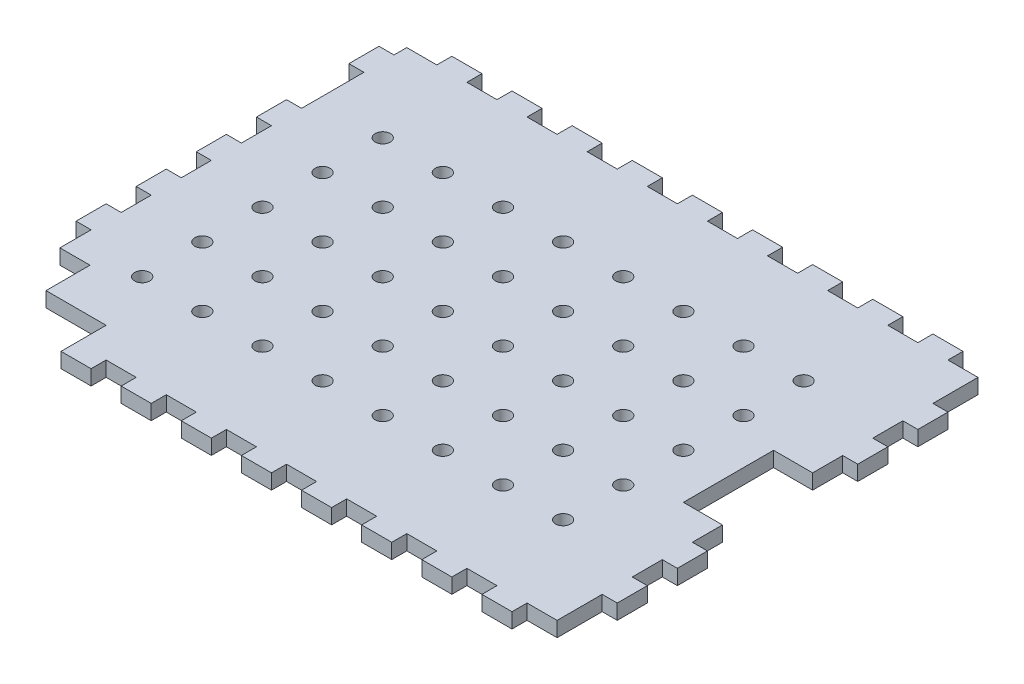
from build123d import *

# Parameters (mm, degrees)
SALIENTE_EXTRUIR1_DEPTH = 5
CROQUIS2_R              = 2.5
CORTAR_EXTRUIR1_DEPTH   = 10


with BuildPart() as part:
    # Croquis1 → Saliente-Extruir1 (new body)
    with BuildSketch(Plane(origin=(0, 0, 0), x_dir=(1, 0, 0), z_dir=(0, 1, 0))):
        Polygon((15, 5), (15, 0), (25, 0), (25, 5), (35, 5), (35, 0), (45, 0), (45, 5), (55, 5), (55, 0), (65, 0), (65, 5), (75, 5), (75, 0), (85, 0), (85, 5), (95, 5), (95, 0), (105, 0), (105, 5), (115, 5), (115, 0), (125, 0), (125, 5), (135, 5), (135, 0), (145, 0), (145, 5), (155, 5), (155, 0), (165, 0), (165, 5), (175, 5), (175, 0), (185, 0), (185, 5), (195, 5), (195, 20), (200, 20), (200, 30), (195, 30), (195, 40), (200, 40), (200, 50), (195, 50), (195, 60), (200, 60), (200, 70), (195, 70), (195, 80), (200, 80), (200, 90), (195, 90), (195, 100), (200, 100), (200, 110), (195, 110), (195, 120), (200, 120), (200, 130), (195, 130), (195, 145), (185, 145), (185, 150), (175, 150), (175, 145), (165, 145), (165, 150), (155, 150), (155, 145), (145, 145), (145, 150), (135, 150), (135, 145), (125, 145), (125, 150), (115, 150), (115, 145), (105, 145), (105, 150), (95, 150), (95, 145), (85, 145), (85, 150), (75, 150), (75, 145), (65, 145), (65, 150), (55, 150), (55, 145), (45, 145), (45, 150), (35, 150), (35, 145), (25, 145), (25, 150), (15, 150), (15, 145), (5, 145), (5, 140.75), (0, 140.75), (0, 130.75), (5, 130.75), (5, 110), (0, 110), (0, 100), (5, 100), (5, 90), (0, 90), (0, 80), (5, 80), (5, 70), (0, 70), (0, 60), (5, 60), (5, 50), (0, 50), (0, 40), (5, 40), (5, 19.25), (0, 19.25), (0, 9.25), (5, 9.25), (5, 5), align=None)
    extrude(amount=SALIENTE_EXTRUIR1_DEPTH)

    # Croquis2 → Cortar-Extruir1 (cut)
    with BuildSketch(Plane(origin=(0, 5, 0), x_dir=(1, 0, 0), z_dir=(0, 1, 0))):
        with Locations((27, 115)):
            Circle(CROQUIS2_R)
        with Locations((47, 115)):
            Circle(CROQUIS2_R)
        with Locations((67, 115)):
            Circle(CROQUIS2_R)
        with Locations((87, 115)):
            Circle(CROQUIS2_R)
        with Locations((107, 115)):
            Circle(CROQUIS2_R)
        with Locations((127, 115)):
            Circle(CROQUIS2_R)
        with Locations((147, 115)):
            Circle(CROQUIS2_R)
        with Locations((167, 115)):
            Circle(CROQUIS2_R)
        with Locations((47, 95)):
            Circle(CROQUIS2_R)
        with Locations((67, 95)):
            Circle(CROQUIS2_R)
        with Locations((87, 95)):
            Circle(CROQUIS2_R)
        with Locations((107, 95)):
            Circle(CROQUIS2_R)
        with Locations((127, 95)):
            Circle(CROQUIS2_R)
        with Locations((147, 95)):
            Circle(CROQUIS2_R)
        with Locations((167, 95)):
            Circle(CROQUIS2_R)
        with Locations((47, 75)):
            Circle(CROQUIS2_R)
        with Locations((67, 75)):
            Circle(CROQUIS2_R)
        with Locations((87, 75)):
            Circle(CROQUIS2_R)
        with Locations((107, 75)):
            Circle(CROQUIS2_R)
        with Locations((127, 75)):
            Circle(CROQUIS2_R)
        with Locations((147, 75)):
            Circle(CROQUIS2_R)
        with Locations((167, 75)):
            Circle(CROQUIS2_R)
        with Locations((47, 55)):
            Circle(CROQUIS2_R)
        with Locations((67, 55)):
            Circle(CROQUIS2_R)
        with Locations((87, 55)):
            Circle(CROQUIS2_R)
        with Locations((107, 55)):
            Circle(CROQUIS2_R)
        with Locations((127, 55)):
            Circle(CROQUIS2_R)
        with Locations((147, 55)):
            Circle(CROQUIS2_R)
        with Locations((167, 55)):
            Circle(CROQUIS2_R)
        with Locations((47, 35)):
            Circle(CROQUIS2_R)
        with Locations((67, 35)):
            Circle(CROQUIS2_R)
        with Locations((87, 35)):
            Circle(CROQUIS2_R)
        with Locations((107, 35)):
            Circle(CROQUIS2_R)
        with Locations((127, 35)):
            Circle(CROQUIS2_R)
        with Locations((147, 35)):
            Circle(CROQUIS2_R)
        with Locations((167, 35)):
            Circle(CROQUIS2_R)
        with Locations((27, 95)):
            Circle(CROQUIS2_R)
        with Locations((27, 75)):
            Circle(CROQUIS2_R)
        with Locations((27, 55)):
            Circle(CROQUIS2_R)
        with Locations((27, 35)):
            Circle(CROQUIS2_R)
        Polygon((5, 29.625), (5, 19.25), (0, 19.25), (0, 9.25), (5, 9.25), (5, 5), (15, 5), (15, 0), (25, 0), (25, 5), (35, 5), (35, 15), (15, 15), (15, 29.625), align=None)
        Polygon((195, 90), (200, 90), (200, 80), (195, 80), (195, 70), (200, 70), (200, 60), (195, 60), (182, 60), (182, 90), align=None)
    extrude(amount=-CORTAR_EXTRUIR1_DEPTH, mode=Mode.SUBTRACT)


solid = part.part
